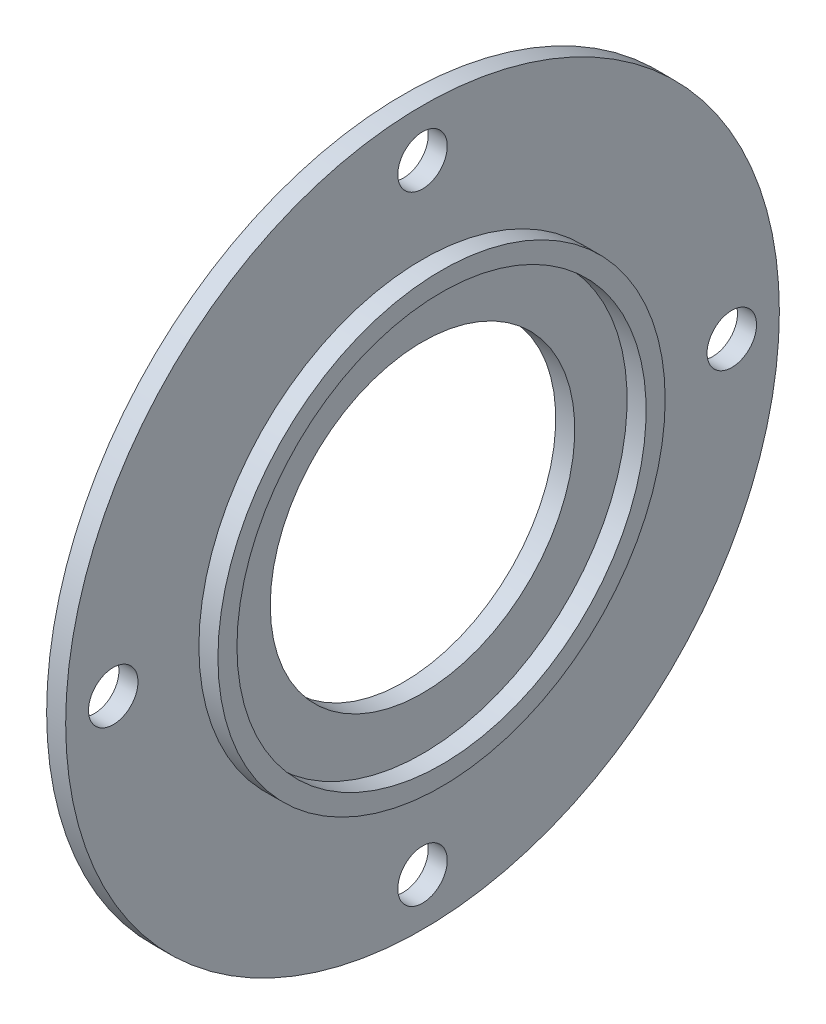
from build123d import *

# Parameters (mm, degrees)
KREISMUSTER1_COUNT = 4


with BuildPart() as part:
    # Skizze1 → Rotation1 (revolve)
    with BuildSketch(Plane.XY):
        Polygon((0, 37.5), (0, 16), (2, 16), (2, 21.5), (4, 21.5), (4, 23.5), (2, 23.5), (2, 37.5), align=None)
    revolve(axis=Axis((-7.743389997, 0, 0), (1, 0, 0)))

    # Skizze7 → Ø5.2 (5.2) Durchmesser Bohrung1 (revolve, cut)
    with BuildSketch(Plane.ZX.offset(32.5)):
        Polygon((0, 0), (0, 31.562237609), (2.6, 30), (2.6, 0), align=None)
    f_5_2_5_2_durchmesser_bohrung1 = revolve(axis=Axis((-6.35, 32.5, 0), (1, 0, 0)), mode=Mode.SUBTRACT)

    # Kreismuster1: Ø5.2 (5.2) Durchmesser Bohrung1 ×4 about axis
    kreismuster1_axis = Axis((0, 0, 0), (1, 0, 0))
    for i in range(1, KREISMUSTER1_COUNT):
        add(f_5_2_5_2_durchmesser_bohrung1.rotate(kreismuster1_axis, i * 360 / KREISMUSTER1_COUNT), mode=Mode.SUBTRACT)


solid = part.part
